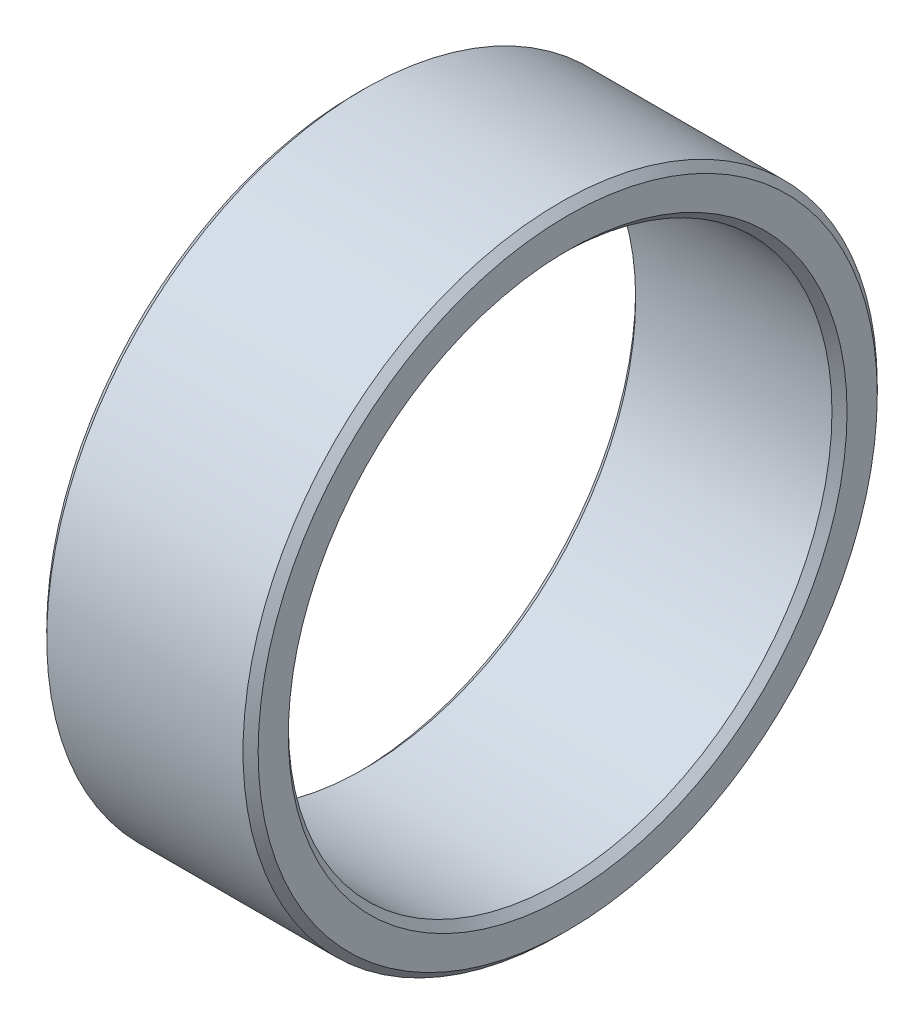
from build123d import *

# Parameters (mm, degrees)
SKETCH_1_R      = 21
SKETCH_1_R_2    = 18
EXTRUDE_1_DEPTH = 14
CHAMFER_1_SIZE  = 0.5


with BuildPart() as part:
    # 草图1 → 凸台-拉伸1 (new body)
    with BuildSketch(Plane(origin=(0, 0, 0), x_dir=(0, 0, -1), z_dir=(1, 0, 0))):
        Circle(SKETCH_1_R)
        Circle(SKETCH_1_R_2, mode=Mode.SUBTRACT)
    extrude(amount=EXTRUDE_1_DEPTH)

    # 倒角1
    chamfer_1_edges = [part.edges().sort_by_distance(p)[0] for p in [
        (0, 0, 21),
        (14, 0, 21),
        (0, 0, 18),
        (14, 0, 18),
    ]]
    chamfer(chamfer_1_edges, length=CHAMFER_1_SIZE)


solid = part.part
